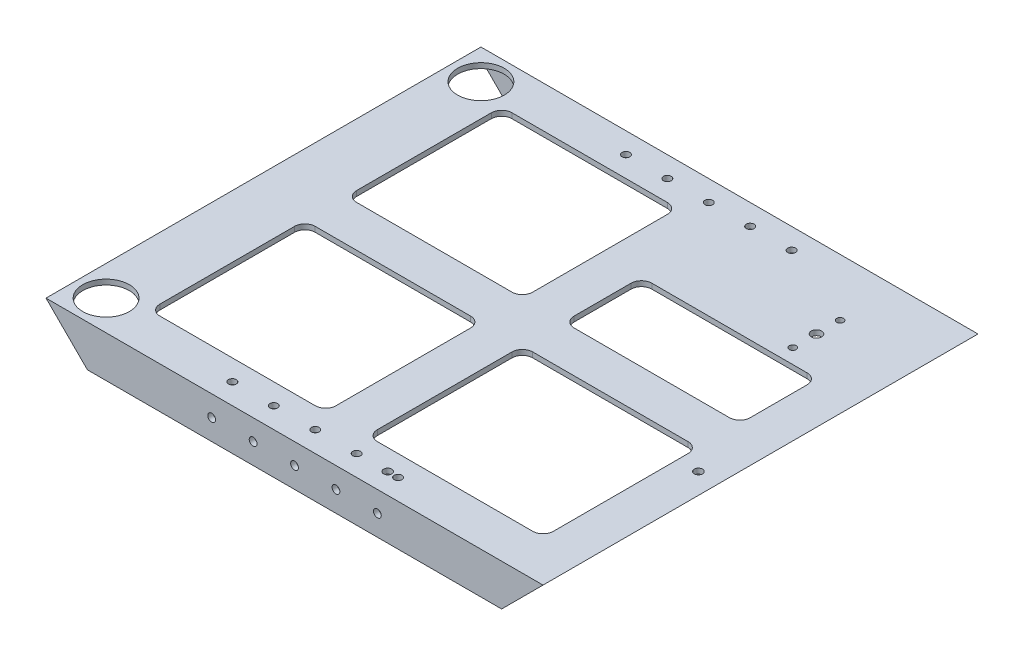
from build123d import *

# Parameters (mm, degrees)
SKETCH2_W           = 304.8
SKETCH2_H           = 266.7
BOSS_EXTRUDE1_DEPTH = 25.4
SKETCH12_W          = 260.35
SKETCH12_H          = 22.225
CUT_EXTRUDE8_DEPTH  = 305.8
CUT_EXTRUDE9_DEPTH  = 267.7
SKETCH14_R          = 14.2875
SKETCH14_R_2        = 3.175
CUT_EXTRUDE10_DEPTH = 4.175
CUT_EXTRUDE11_DEPTH = 3.175
SKETCH16_R          = 2.38125
CUT_EXTRUDE12_DEPTH = 267.7
SKETCH17_R          = 2.38125
CUT_EXTRUDE13_DEPTH = 26.4
SKETCH18_R          = 2.0955
CUT_EXTRUDE14_DEPTH = 3.175
SKETCH19_R          = 2.54
CUT_EXTRUDE15_DEPTH = 26.4
SKETCH20_R          = 2.54
CUT_EXTRUDE16_DEPTH = 26.4


with BuildPart() as part:
    # Sketch2 → Boss-Extrude1 (new body)
    with BuildSketch(Plane(origin=(0, 0, 0), x_dir=(1, 0, 0), z_dir=(0, 1, 0))):
        with Locations((152.4, 133.35)):
            Rectangle(SKETCH2_W, SKETCH2_H)
    extrude(amount=BOSS_EXTRUDE1_DEPTH)

    # Sketch12 → Cut-Extrude8 (cut, through all)
    with BuildSketch(Plane(origin=(304.8, 0, 0), x_dir=(0, 0, -1), z_dir=(1, 0, 0))):
        with Locations((133.35, 11.1125)):
            Rectangle(SKETCH12_W, SKETCH12_H)
    extrude(amount=-CUT_EXTRUDE8_DEPTH, mode=Mode.SUBTRACT)

    # Sketch13 → Cut-Extrude9 (cut, through all)
    with BuildSketch(Plane.XY):
        Polygon((304.8, 25.4), (279.4, 0), (304.8, 0), align=None)
        Polygon((0, 0), (0, 25.4), (25.4, 0), align=None)
    extrude(amount=-CUT_EXTRUDE9_DEPTH, mode=Mode.SUBTRACT)

    # Sketch14 → Cut-Extrude10 (cut, through all)
    with BuildSketch(Plane.XZ.offset(-22.225)):
        with Locations((18.415, -18.415)):
            Circle(SKETCH14_R)
        with Locations((18.415, -248.285)):
            Circle(SKETCH14_R)
        with Locations((255.27, -217.17)):
            Circle(SKETCH14_R_2)
    extrude(amount=-CUT_EXTRUDE10_DEPTH, mode=Mode.SUBTRACT)

    # Sketch15 → Cut-Extrude11 (cut)
    with BuildSketch(Plane(origin=(0, 25.4, 0), x_dir=(1, 0, 0), z_dir=(0, 1, 0))):
        with BuildLine():
            Line((44.45, 241.3), (139.7, 241.3))
            ThreePointArc((139.7, 241.3), (144.190128061, 239.440128061), (146.05, 234.95))
            Line((146.05, 234.95), (146.05, 152.4))
            ThreePointArc((146.05, 152.4), (144.190128061, 147.909871939), (139.7, 146.05))
            Line((139.7, 146.05), (44.45, 146.05))
            ThreePointArc((44.45, 146.05), (39.959871939, 147.909871939), (38.1, 152.4))
            Line((38.1, 152.4), (38.1, 234.95))
            ThreePointArc((38.1, 234.95), (39.959871939, 239.440128061), (44.45, 241.3))
        make_face()
        with BuildLine():
            Line((44.45, 120.65), (139.7, 120.65))
            ThreePointArc((139.7, 120.65), (144.190128061, 118.790128061), (146.05, 114.3))
            Line((146.05, 114.3), (146.05, 31.75))
            ThreePointArc((146.05, 31.75), (144.190128061, 27.259871939), (139.7, 25.4))
            Line((139.7, 25.4), (44.45, 25.4))
            ThreePointArc((44.45, 25.4), (39.959871939, 27.259871939), (38.1, 31.75))
            Line((38.1, 31.75), (38.1, 114.3))
            ThreePointArc((38.1, 114.3), (39.959871939, 118.790128061), (44.45, 120.65))
        make_face()
        with BuildLine():
            Line((177.8, 193.675), (273.05, 193.675))
            ThreePointArc((273.05, 193.675), (277.540128061, 191.815128061), (279.4, 187.325))
            Line((279.4, 187.325), (279.4, 152.4))
            ThreePointArc((279.4, 152.4), (277.540128061, 147.909871939), (273.05, 146.05))
            Line((273.05, 146.05), (177.8, 146.05))
            ThreePointArc((177.8, 146.05), (173.309871939, 147.909871939), (171.45, 152.4))
            Line((171.45, 152.4), (171.45, 187.325))
            ThreePointArc((171.45, 187.325), (173.309871939, 191.815128061), (177.8, 193.675))
        make_face()
        with BuildLine():
            Line((177.8, 120.65), (273.05, 120.65))
            ThreePointArc((273.05, 120.65), (277.540128061, 118.790128061), (279.4, 114.3))
            Line((279.4, 114.3), (279.4, 31.75))
            ThreePointArc((279.4, 31.75), (277.540128061, 27.259871939), (273.05, 25.4))
            Line((273.05, 25.4), (177.8, 25.4))
            ThreePointArc((177.8, 25.4), (173.309871939, 27.259871939), (171.45, 31.75))
            Line((171.45, 31.75), (171.45, 114.3))
            ThreePointArc((171.45, 114.3), (173.309871939, 118.790128061), (177.8, 120.65))
        make_face()
    extrude(amount=-CUT_EXTRUDE11_DEPTH, mode=Mode.SUBTRACT)

    # Sketch16 → Cut-Extrude12 (cut, through all)
    with BuildSketch(Plane.XY):
        with Locations((152.4, 12.7)):
            Circle(SKETCH16_R)
        with Locations((127, 12.7)):
            Circle(SKETCH16_R)
        with Locations((101.6, 12.7)):
            Circle(SKETCH16_R)
        with Locations((177.8, 12.7)):
            Circle(SKETCH16_R)
        with Locations((203.2, 12.7)):
            Circle(SKETCH16_R)
    extrude(amount=-CUT_EXTRUDE12_DEPTH, mode=Mode.SUBTRACT)

    # Sketch17 → Cut-Extrude13 (cut, through all)
    with BuildSketch(Plane(origin=(0, 25.4, 0), x_dir=(1, 0, 0), z_dir=(0, 1, 0))):
        with Locations((152.4, 12.7)):
            Circle(SKETCH17_R)
        with Locations((177.8, 12.7)):
            Circle(SKETCH17_R)
        with Locations((203.2, 12.7)):
            Circle(SKETCH17_R)
        with Locations((127, 12.7)):
            Circle(SKETCH17_R)
        with Locations((101.6, 12.7)):
            Circle(SKETCH17_R)
        with Locations((203.2, 254)):
            Circle(SKETCH17_R)
        with Locations((177.8, 254)):
            Circle(SKETCH17_R)
        with Locations((152.4, 254)):
            Circle(SKETCH17_R)
        with Locations((127, 254)):
            Circle(SKETCH17_R)
        with Locations((101.6, 254)):
            Circle(SKETCH17_R)
    extrude(amount=-CUT_EXTRUDE13_DEPTH, mode=Mode.SUBTRACT)

    # Sketch18 → Cut-Extrude14 (cut)
    with BuildSketch(Plane(origin=(0, 25.4, 0), x_dir=(1, 0, 0), z_dir=(0, 1, 0))):
        with Locations((255.27, 231.6734)):
            Circle(SKETCH18_R)
        with Locations((255.27, 202.6666)):
            Circle(SKETCH18_R)
    extrude(amount=-CUT_EXTRUDE14_DEPTH, mode=Mode.SUBTRACT)

    # Sketch19 → Cut-Extrude15 (cut, through all)
    with BuildSketch(Plane(origin=(0, 25.4, 0), x_dir=(1, 0, 0), z_dir=(0, 1, 0))):
        with Locations((196.85, 12.7)):
            Circle(SKETCH19_R)
    extrude(amount=-CUT_EXTRUDE15_DEPTH, mode=Mode.SUBTRACT)

    # Sketch20 → Cut-Extrude16 (cut, through all)
    with BuildSketch(Plane(origin=(0, 25.4, 0), x_dir=(1, 0, 0), z_dir=(0, 1, 0))):
        with Locations((292.1, 107.95)):
            Circle(SKETCH20_R)
    extrude(amount=-CUT_EXTRUDE16_DEPTH, mode=Mode.SUBTRACT)


solid = part.part
